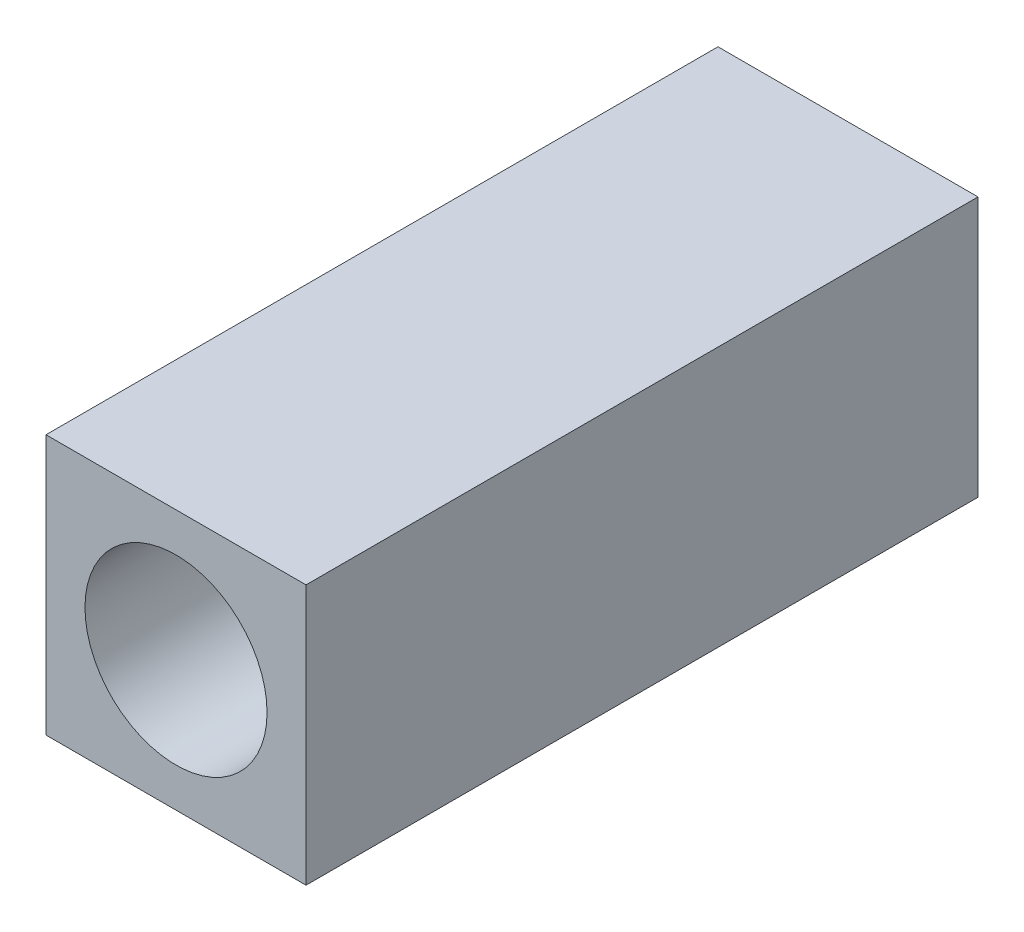
from build123d import *

# Parameters (mm, degrees)
BOSS_EXTRUDE1_DEPTH   = 16
M5_TAPPED_HOLE1_D     = 4.2
M5_TAPPED_HOLE1_DEPTH = 14
M5_TAPPED_HOLE1_TIP   = 1.2618073
CHAMFER1_SIZE         = 0.5


with BuildPart() as part:
    # Sketch1 → Boss-Extrude1 (new body)
    with BuildSketch(Plane.XY):
        with BuildLine():
            Line((-2.998955183, 3), (-2.998955183, 0.079169503))
            ThreePointArc((-2.998955183, 0.079169503), (-2.093142553, 2.14912872), (0, 3))
            Line((0, 3), (-2.998955183, 3))
        make_face()
        with BuildLine():
            ThreePointArc((0, 3), (2.093142553, 2.14912872), (2.998955183, 0.079169503))
            Line((2.998955183, 0.079169503), (2.998955183, 3))
            Line((2.998955183, 3), (0, 3))
        make_face()
        with BuildLine():
            ThreePointArc((-2.998955183, -0.079169503), (-2.093142553, -2.14912872), (0, -3))
            ThreePointArc((0, -3), (2.093142553, -2.14912872), (2.998955183, -0.079169503))
            Line((2.998955183, -0.079169503), (2.998955183, 0.079169503))
            ThreePointArc((2.998955183, 0.079169503), (2.093142553, 2.14912872), (0, 3))
            ThreePointArc((0, 3), (-2.093142553, 2.14912872), (-2.998955183, 0.079169503))
            Line((-2.998955183, 0.079169503), (-2.998955183, -0.079169503))
        make_face()
        with BuildLine():
            ThreePointArc((2.998955183, -0.079169503), (2.093142553, -2.14912872), (0, -3))
            Line((0, -3), (2.998955183, -3))
            Line((2.998955183, -3), (2.998955183, -0.079169503))
        make_face()
        with BuildLine():
            Line((-2.998955183, -0.079169503), (-2.998955183, -3))
            Line((-2.998955183, -3), (0, -3))
            ThreePointArc((0, -3), (-2.093142553, -2.14912872), (-2.998955183, -0.079169503))
        make_face()
    extrude(amount=BOSS_EXTRUDE1_DEPTH)

    # M5 Tapped Hole1
    with Locations(Plane.XY.offset(16)):
        with Locations((0, 0)):
            Hole(M5_TAPPED_HOLE1_D / 2, depth=M5_TAPPED_HOLE1_DEPTH)
            with Locations((0, 0, -(M5_TAPPED_HOLE1_DEPTH + M5_TAPPED_HOLE1_TIP / 2))):  # 118° drill point
                Cone(0, M5_TAPPED_HOLE1_D / 2, M5_TAPPED_HOLE1_TIP, mode=Mode.SUBTRACT)

    # Chamfer1
    chamfer1_edges = [part.edges().sort_by_distance(p)[0] for p in [
        (0, 3, 0),
        (2.998955183, 0, 0),
        (0, -3, 0),
        (-2.998955183, 0, 0),
    ]]
    chamfer(chamfer1_edges, length=CHAMFER1_SIZE)


solid = part.part
